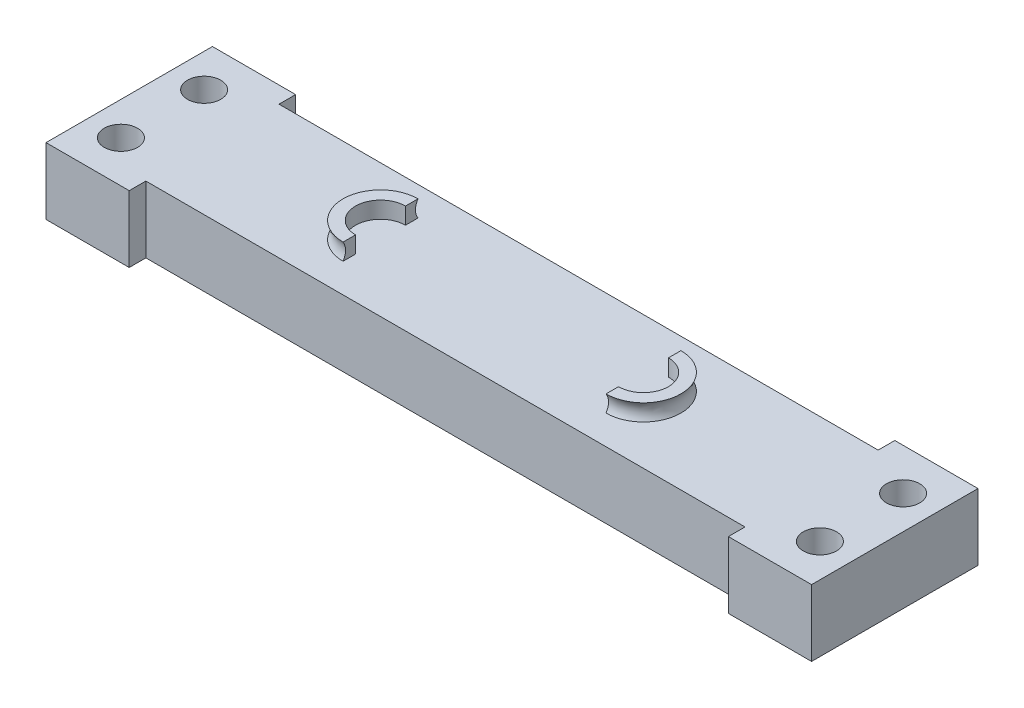
from build123d import *

# Parameters (mm, degrees)
SKETCH_1_R          = 1
EXTRUDE_2_DEPTH     = 4
EXTRUDE_3_DEPTH     = 1
CUT_EXTRUDE_2_DEPTH = 1


with BuildPart() as part:
    # 草图1 → 凸台-拉伸2 (new body)
    with BuildSketch(Plane(origin=(0, 0, 0), x_dir=(1, 0, 0), z_dir=(0, 1, 0))):
        Polygon((-24.994291736, 0), (11.005708264, 0), (11.005708264, 1), (16.005708264, 1), (16.005708264, -9), (11.005708264, -9), (11.005708264, -8), (-24.994291736, -8), (-24.994291736, -9), (-29.994291736, -9), (-29.994291736, 1), (-24.994291736, 1), align=None)
        with Locations((-27.994291736, -6.5)):
            Circle(SKETCH_1_R, mode=Mode.SUBTRACT)
        with Locations((-27.994291736, -1.5)):
            Circle(SKETCH_1_R, mode=Mode.SUBTRACT)
        with Locations((14.005708264, -1.5)):
            Circle(SKETCH_1_R, mode=Mode.SUBTRACT)
        with Locations((14.005708264, -6.5)):
            Circle(SKETCH_1_R, mode=Mode.SUBTRACT)
    extrude(amount=EXTRUDE_2_DEPTH)

    # 草图2 → 凸台-拉伸3 (add)
    with BuildSketch(Plane(origin=(0, 4, 0), x_dir=(1, 0, 0), z_dir=(0, 1, 0))):
        with BuildLine():
            Line((-14.894291736, -1.75), (0.905708264, -1.75))
            ThreePointArc((0.905708264, -1.75), (3.155708264, -4), (0.905708264, -6.25))
            Line((0.905708264, -6.25), (-14.894291736, -6.25))
            ThreePointArc((-14.894291736, -6.25), (-17.144291736, -4), (-14.894291736, -1.75))
        make_face()
    extrude(amount=EXTRUDE_3_DEPTH)

    # 草图3 → 切除-拉伸2 (cut)
    with BuildSketch(Plane(origin=(0, 5, 0), x_dir=(1, 0, 0), z_dir=(0, 1, 0))):
        with BuildLine():
            Line((-14.894291736, -2.5), (-14.894291736, -1.75))
            Line((-14.894291736, -1.75), (0.905708264, -1.75))
            Line((0.905708264, -1.75), (0.905708264, -2.5))
            ThreePointArc((0.905708264, -2.5), (2.405708264, -4), (0.905708264, -5.5))
            Line((0.905708264, -5.5), (0.905708264, -6.25))
            Line((0.905708264, -6.25), (-14.894291736, -6.25))
            Line((-14.894291736, -6.25), (-14.894291736, -5.5))
            ThreePointArc((-14.894291736, -5.5), (-16.394291736, -4), (-14.894291736, -2.5))
        make_face()
    extrude(amount=-CUT_EXTRUDE_2_DEPTH, mode=Mode.SUBTRACT)

    # 切除-扫描2: sweep along a path in 草图5
    with BuildLine(Plane(origin=(0, 5, 0), x_dir=(1, 0, 0), z_dir=(0, 1, 0))) as sweep_2_path:
        CenterArc((-14.894291736, -4), 2.25, 0, 360)
    # 草图4 → 切除-扫描2 (sweep, cut)
    with BuildSketch(Plane(origin=(-14.894291736, 0, 0), x_dir=(0, 0, -1), z_dir=(1, 0, 0))):
        with BuildLine():
            Line((-6.25, 5), (-6.25, 4))
            add(Edge.make_bspline(
                [(-6.25, 5), (-5.95, 4.5), (-6.25, 4)],
                knots=[0, 0, 0, 1, 1, 1], degree=2))
        make_face()
    sweep(path=sweep_2_path.line, mode=Mode.SUBTRACT)

    # 切除-扫描3: sweep along a path in 草图9
    with BuildLine(Plane(origin=(0, 5, 0), x_dir=(1, 0, 0), z_dir=(0, 1, 0))) as sweep_3_path:
        CenterArc((0.905708264, -4), 2.25, 0, 360)
    # 草图8 → 切除-扫描3 (sweep, cut)
    with BuildSketch(Plane.ZY.offset(-0.905708264)):
        with BuildLine():
            Line((6.25, 4), (6.25, 5))
            add(Edge.make_bspline(
                [(6.25, 4), (5.95, 4.5), (6.25, 5)],
                knots=[0, 0, 0, 1, 1, 1], degree=2))
        make_face()
    sweep(path=sweep_3_path.line, mode=Mode.SUBTRACT)


solid = part.part
